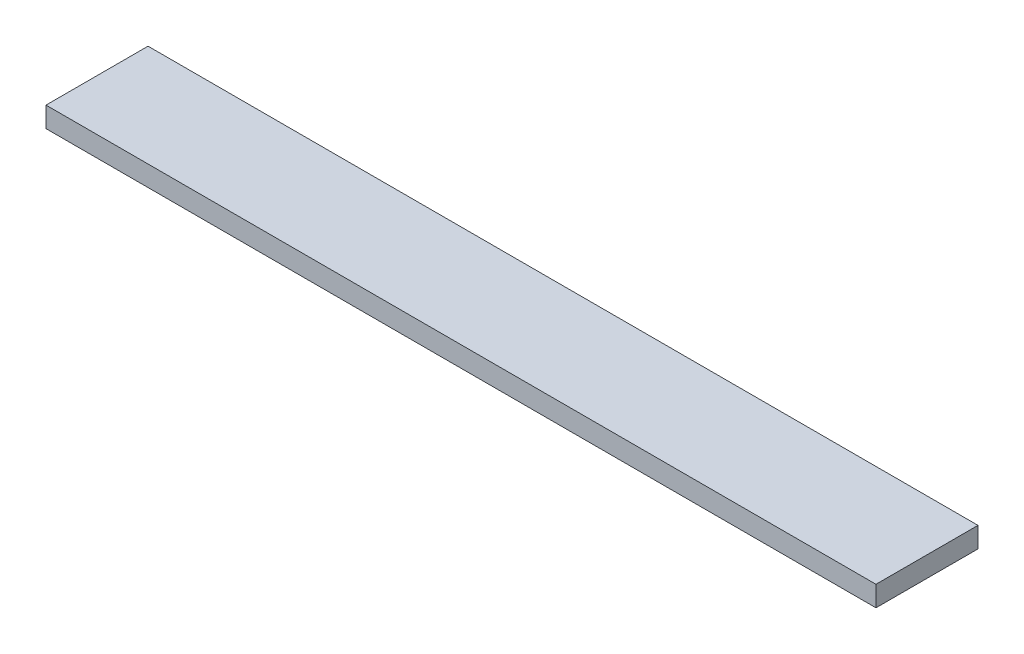
from build123d import *

# Parameters (mm, degrees)
SKETCH1_W           = 122
SKETCH1_H           = 15
BOSS_EXTRUDE1_DEPTH = 3


with BuildPart() as part:
    # Sketch1 → Boss-Extrude1 (new body)
    with BuildSketch(Plane(origin=(0, 0, 0), x_dir=(1, 0, 0), z_dir=(0, 1, 0))):
        with Locations((61, 7.5)):
            Rectangle(SKETCH1_W, SKETCH1_H)
    extrude(amount=BOSS_EXTRUDE1_DEPTH)


solid = part.part
